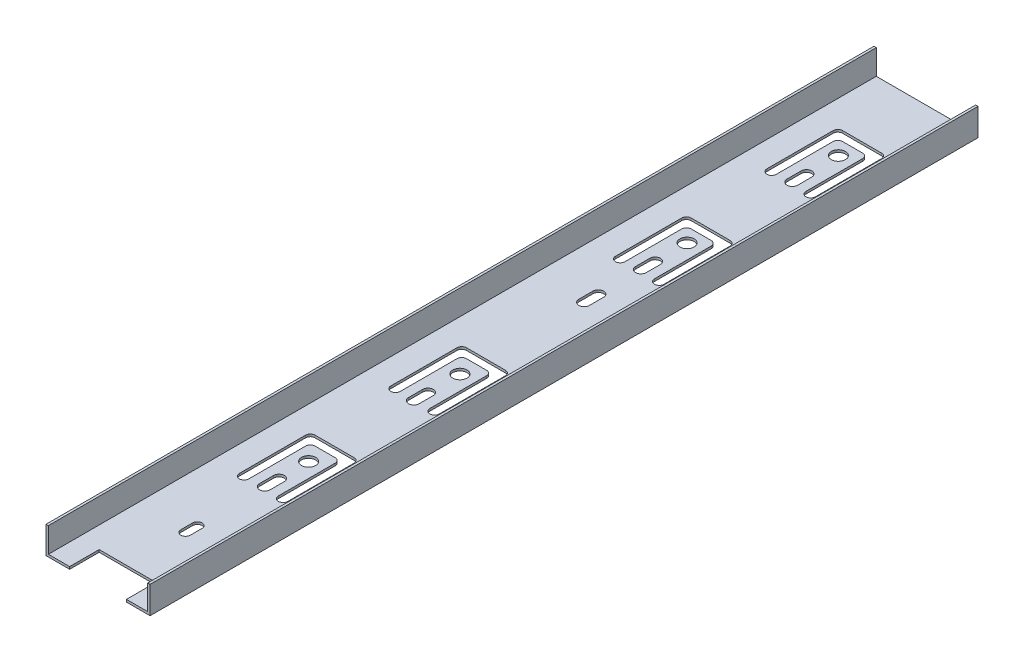
from build123d import *

# Parameters (mm, degrees)
EXTRUDE_1_DEPTH     = 350
SKETCH_2_R          = 3
SKETCH_2_W          = 24
SKETCH_2_H          = 12.465583579
CUT_EXTRUDE_1_DEPTH = 350


with BuildPart() as part:
    # 草图1 → 凸台-拉伸1 (new body)
    with BuildSketch(Plane.XY):
        Polygon((-34.186090226, 5.411678692), (-33.186090226, 5.411678692), (-33.186090226, -5.088321308), (8.813909774, -5.088321308), (8.813909774, 5.411678692), (9.813909774, 5.411678692), (9.813909774, -6.088321308), (-34.186090226, -6.088321308), align=None)
    extrude(amount=EXTRUDE_1_DEPTH)

    # 草图2 → 切除-拉伸1 (cut)
    with BuildSketch(Plane.XZ.offset(6.088321308)):
        with Locations((-12.186090226, 261)):
            Circle(SKETCH_2_R)
        with Locations((-12.186090226, 197)):
            Circle(SKETCH_2_R)
        with Locations((-12.186090226, 101)):
            Circle(SKETCH_2_R)
        with Locations((-12.186090226, 37)):
            Circle(SKETCH_2_R)
        with BuildLine():
            Line((-22.436090226, 280), (-22.436090226, 252))
            ThreePointArc((-22.436090226, 252), (-21.850303788, 250.585786438), (-20.436090226, 250))
            Line((-20.436090226, 250), (-3.936090226, 250))
            ThreePointArc((-3.936090226, 250), (-2.521876663, 250.585786438), (-1.936090226, 252))
            Line((-1.936090226, 252), (-1.936090226, 280))
            ThreePointArc((-1.936090226, 280), (-3.936090226, 282), (-5.936090226, 280))
            Line((-5.936090226, 280), (-5.936090226, 256))
            ThreePointArc((-5.936090226, 256), (-6.521876663, 254.585786438), (-7.936090226, 254))
            Line((-7.936090226, 254), (-16.436090226, 254))
            ThreePointArc((-16.436090226, 254), (-17.850303788, 254.585786438), (-18.436090226, 256))
            Line((-18.436090226, 256), (-18.436090226, 280))
            ThreePointArc((-18.436090226, 280), (-20.436090226, 282), (-22.436090226, 280))
        make_face()
        with BuildLine():
            Line((-14.436090226, 279.5), (-14.436090226, 273.5))
            ThreePointArc((-14.436090226, 273.5), (-12.186090226, 271.25), (-9.936090226, 273.5))
            Line((-9.936090226, 273.5), (-9.936090226, 279.5))
            ThreePointArc((-9.936090226, 279.5), (-12.186090226, 281.75), (-14.436090226, 279.5))
        make_face()
        with BuildLine():
            Line((-5.936090226, 216), (-5.936090226, 192))
            ThreePointArc((-5.936090226, 192), (-6.521876663, 190.585786438), (-7.936090226, 190))
            Line((-7.936090226, 190), (-16.436090226, 190))
            ThreePointArc((-16.436090226, 190), (-17.850303788, 190.585786438), (-18.436090226, 192))
            Line((-18.436090226, 192), (-18.436090226, 216))
            ThreePointArc((-18.436090226, 216), (-20.436090226, 218), (-22.436090226, 216))
            Line((-22.436090226, 216), (-22.436090226, 188))
            ThreePointArc((-22.436090226, 188), (-21.850303788, 186.585786438), (-20.436090226, 186))
            Line((-20.436090226, 186), (-3.936090226, 186))
            ThreePointArc((-3.936090226, 186), (-2.521876663, 186.585786438), (-1.936090226, 188))
            Line((-1.936090226, 188), (-1.936090226, 216))
            ThreePointArc((-1.936090226, 216), (-3.936090226, 218), (-5.936090226, 216))
        make_face()
        with BuildLine():
            Line((-14.436090226, 216.5), (-14.436090226, 210.5))
            ThreePointArc((-14.436090226, 210.5), (-12.186090226, 208.25), (-9.936090226, 210.5))
            Line((-9.936090226, 210.5), (-9.936090226, 216.5))
            ThreePointArc((-9.936090226, 216.5), (-12.186090226, 218.75), (-14.436090226, 216.5))
        make_face()
        with BuildLine():
            Line((-20.436090226, 91), (-3.936090226, 91))
            ThreePointArc((-3.936090226, 91), (-2.521876663, 91.585786438), (-1.936090226, 93))
            Line((-1.936090226, 93), (-1.936090226, 121))
            ThreePointArc((-1.936090226, 121), (-3.936090226, 123), (-5.936090226, 121))
            Line((-5.936090226, 121), (-5.936090226, 97))
            ThreePointArc((-5.936090226, 97), (-6.521876663, 95.585786438), (-7.936090226, 95))
            Line((-7.936090226, 95), (-16.436090226, 95))
            ThreePointArc((-16.436090226, 95), (-17.850303788, 95.585786438), (-18.436090226, 97))
            Line((-18.436090226, 97), (-18.436090226, 121))
            ThreePointArc((-18.436090226, 121), (-20.436090226, 123), (-22.436090226, 121))
            Line((-22.436090226, 121), (-22.436090226, 93))
            ThreePointArc((-22.436090226, 93), (-21.850303788, 91.585786438), (-20.436090226, 91))
        make_face()
        with BuildLine():
            Line((-9.936090226, 120.5), (-9.936090226, 114.5))
            ThreePointArc((-9.936090226, 114.5), (-12.186090226, 112.25), (-14.436090226, 114.5))
            Line((-14.436090226, 114.5), (-14.436090226, 120.5))
            ThreePointArc((-14.436090226, 120.5), (-12.186090226, 122.75), (-9.936090226, 120.5))
        make_face()
        with BuildLine():
            Line((-20.436090226, 27), (-3.936090226, 27))
            ThreePointArc((-3.936090226, 27), (-2.521876663, 27.585786438), (-1.936090226, 29))
            Line((-1.936090226, 29), (-1.936090226, 57))
            ThreePointArc((-1.936090226, 57), (-3.936090226, 59), (-5.936090226, 57))
            Line((-5.936090226, 57), (-5.936090226, 33))
            ThreePointArc((-5.936090226, 33), (-6.521876663, 31.585786438), (-7.936090226, 31))
            Line((-7.936090226, 31), (-16.436090226, 31))
            ThreePointArc((-16.436090226, 31), (-17.850303788, 31.585786438), (-18.436090226, 33))
            Line((-18.436090226, 33), (-18.436090226, 57))
            ThreePointArc((-18.436090226, 57), (-20.436090226, 59), (-22.436090226, 57))
            Line((-22.436090226, 57), (-22.436090226, 29))
            ThreePointArc((-22.436090226, 29), (-21.850303788, 27.585786438), (-20.436090226, 27))
        make_face()
        with BuildLine():
            Line((-9.936090226, 56.5), (-9.936090226, 50.5))
            ThreePointArc((-9.936090226, 50.5), (-12.186090226, 48.25), (-14.436090226, 50.5))
            Line((-14.436090226, 50.5), (-14.436090226, 56.5))
            ThreePointArc((-14.436090226, 56.5), (-12.186090226, 58.75), (-9.936090226, 56.5))
        make_face()
        with BuildLine():
            Line((-14.186090226, 313), (-14.186090226, 308))
            ThreePointArc((-14.186090226, 308), (-12.186090226, 306), (-10.186090226, 308))
            Line((-10.186090226, 308), (-10.186090226, 313))
            ThreePointArc((-10.186090226, 313), (-12.186090226, 315), (-14.186090226, 313))
        make_face()
        with BuildLine():
            Line((-14.436090226, 144.5), (-14.436090226, 138.5))
            ThreePointArc((-14.436090226, 138.5), (-12.186090226, 136.25), (-9.936090226, 138.5))
            Line((-9.936090226, 138.5), (-9.936090226, 144.5))
            ThreePointArc((-9.936090226, 144.5), (-12.186090226, 146.75), (-14.436090226, 144.5))
        make_face()
        with Locations((-12.186090226, 343.767208211)):
            Rectangle(SKETCH_2_W, SKETCH_2_H)
    extrude(amount=-CUT_EXTRUDE_1_DEPTH, mode=Mode.SUBTRACT)


solid = part.part
